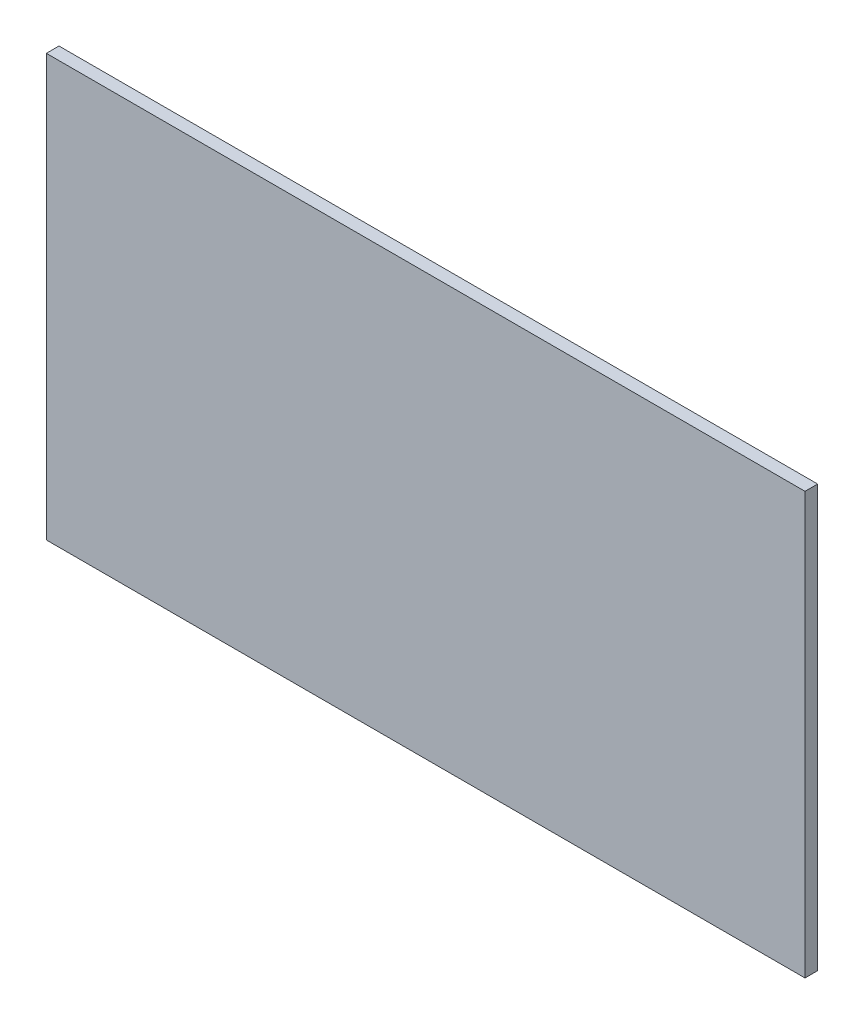
from build123d import *

# Parameters (mm, degrees)
CROQUIS1_W              = 180
CROQUIS1_H              = 100
SALIENTE_EXTRUIR1_DEPTH = 3


with BuildPart() as part:
    # Croquis1 → Saliente-Extruir1 (new body)
    with BuildSketch(Plane.XY):
        with Locations((90, 50)):
            Rectangle(CROQUIS1_W, CROQUIS1_H)
    extrude(amount=SALIENTE_EXTRUIR1_DEPTH)


solid = part.part
